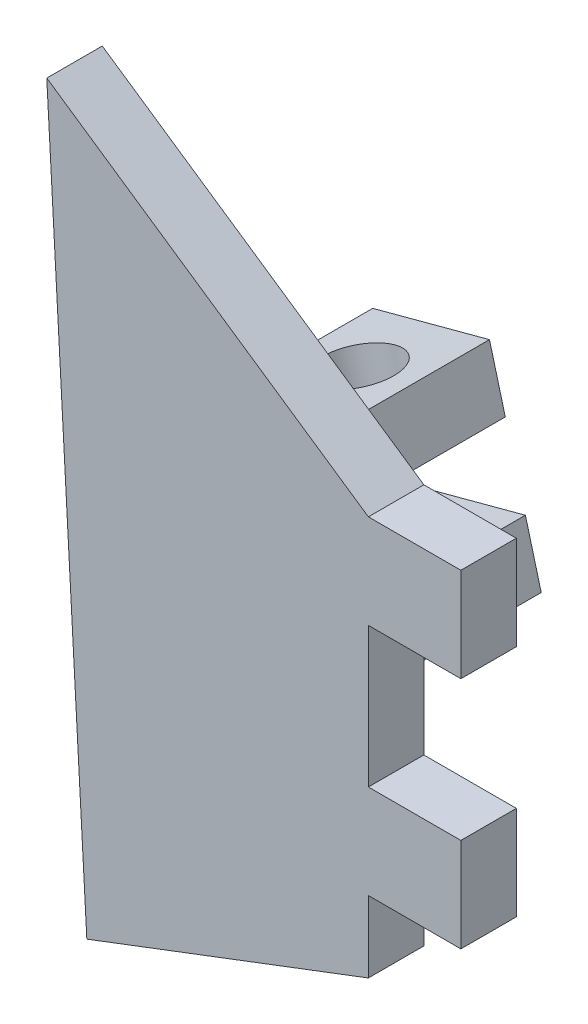
from build123d import *

# Parameters (mm, degrees)
BOSS_EXTRUDE1_DEPTH = 3
BOSS_EXTRUDE2_DEPTH = 12
SKETCH8_R           = 2
CUT_EXTRUDE2_DEPTH  = 27.616080544


with BuildPart() as part:
    # Sketch1 → Boss-Extrude1 (new body)
    with BuildSketch(Plane.XY):
        Polygon((15.219519397, 37.989351506), (20.219519397, 37.989351506), (20.219519397, 32.909351506), (15.219519397, 32.909351506), (15.219519397, 25.341157087), (20.219519397, 25.341157087), (20.219519397, 20.261157087), (15.219519397, 20.261157087), (15.219519397, 16.399351506), (0, 10.609645279), (-2.165979283, 49.840454802), align=None)
    extrude(amount=BOSS_EXTRUDE1_DEPTH)

    # Sketch7 → Boss-Extrude2 (add)
    with BuildSketch(Plane(origin=(0, 0, 0), x_dir=(-1, 0, 0), z_dir=(0, 0, -1))):
        Polygon((-7.622037061, 31.367483037), (-6.766619255, 34.559945753), (-0.453977977, 32.868478621), (-1.309395784, 29.676015905), align=None)
        Polygon((-8.709077051, 27.310594567), (-2.396435773, 25.619127434), (-3.25185358, 22.426664718), (-9.564494858, 24.118131851), align=None)
    extrude(amount=BOSS_EXTRUDE2_DEPTH)

    # Sketch8 → Cut-Extrude2 (cut, through all)
    with BuildSketch(Plane(origin=(-8.186708897, 30.553213551, 0), x_dir=(0.965925826, 0.258819045, 0), z_dir=(-0.258819045, 0.965925826, 0))):
        with Locations((12.213160878, 8.044397723)):
            Circle(SKETCH8_R)
    extrude(amount=-CUT_EXTRUDE2_DEPTH, mode=Mode.SUBTRACT)


solid = part.part
